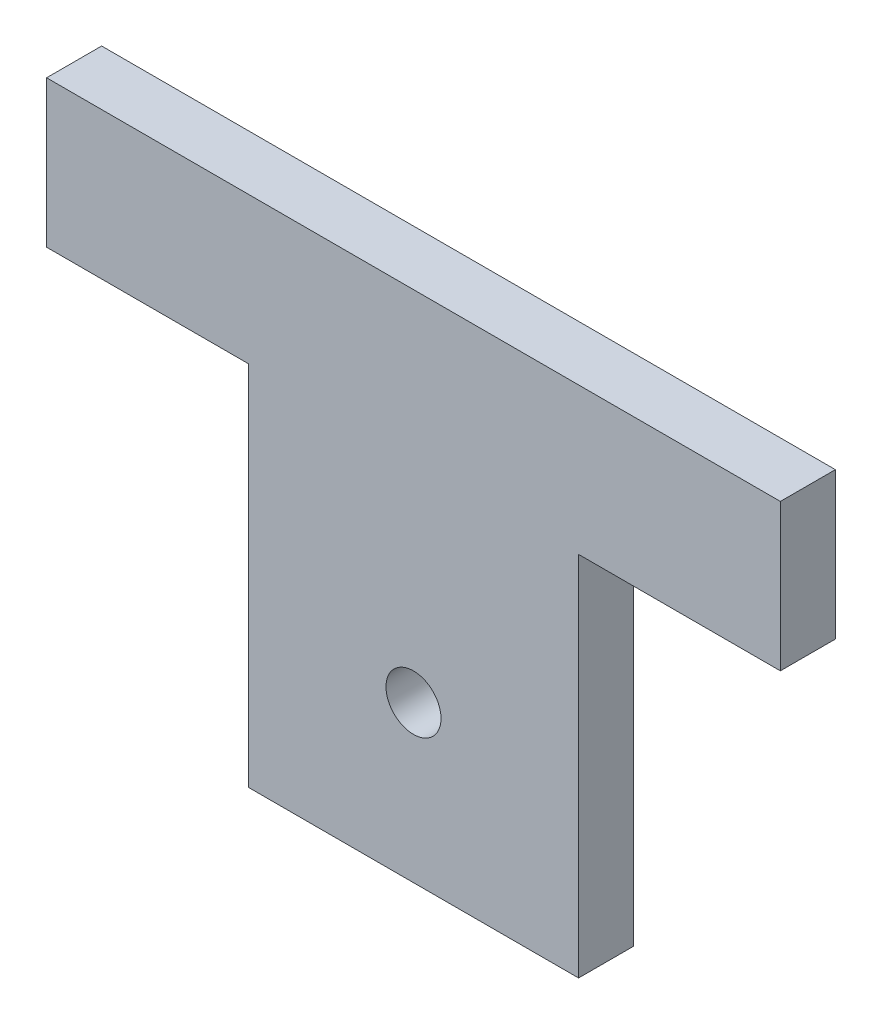
from build123d import *

# Parameters (mm, degrees)
SKETCH1_R           = 1.5
BOSS_EXTRUDE1_DEPTH = 3


with BuildPart() as part:
    # Sketch1 → Boss-Extrude1 (new body)
    with BuildSketch(Plane.XY):
        Polygon((20, 8), (-20, 8), (-20, 0), (-9, 0), (-9, -20), (9, -20), (9, 0), (20, 0), align=None)
        with Locations((0, -11.5)):
            Circle(SKETCH1_R, mode=Mode.SUBTRACT)
    extrude(amount=BOSS_EXTRUDE1_DEPTH)


solid = part.part
